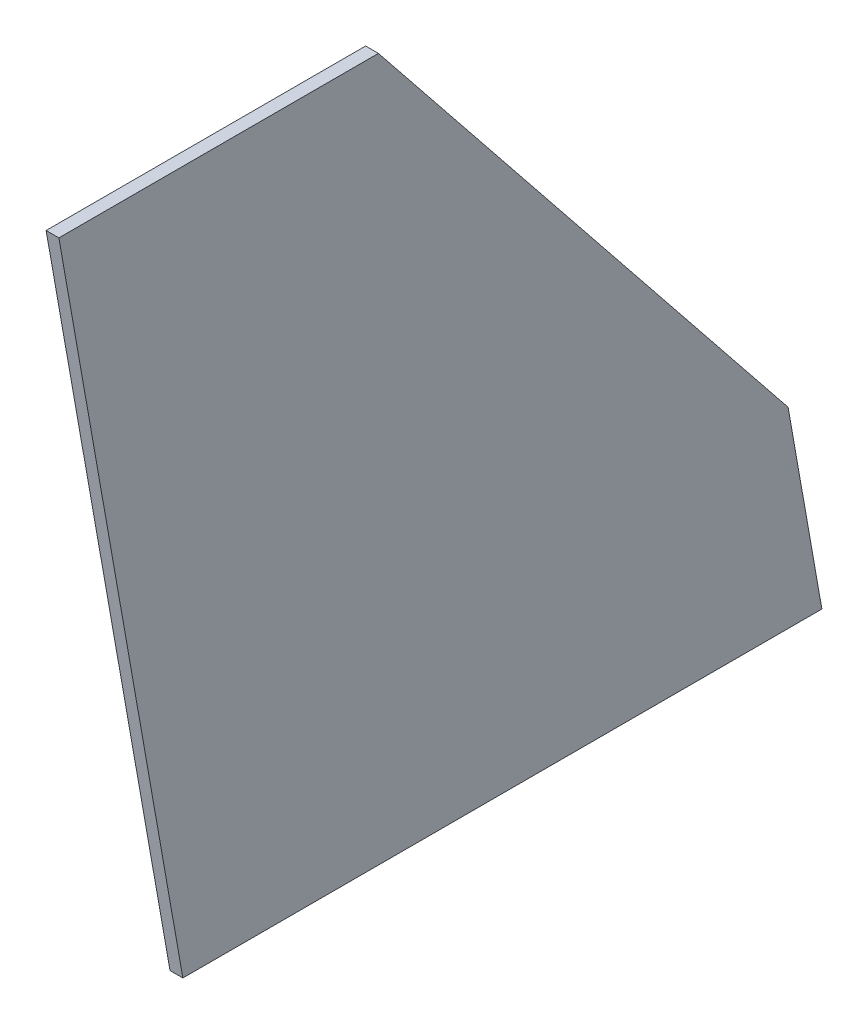
from build123d import *

# Parameters (mm, degrees)
BOSS_EXTRUDE1_DEPTH      = 1.27
BOSS_EXTRUDE1_DEPTH_BACK = 1.27


with BuildPart() as part:
    # Sketch1 → Boss-Extrude1 (new, two sides: drawn at the far end of the back side and taken through both)
    with BuildSketch(Plane(origin=(0, 0, 0), x_dir=(0, 0, -1), z_dir=(1, 0, 0)).offset(-BOSS_EXTRUDE1_DEPTH_BACK)):
        Polygon((0, 0), (127, 0), (120.281942035, 38.1), (38.867120795, 139.7), (-24.632879205, 139.7), align=None)
    extrude(amount=BOSS_EXTRUDE1_DEPTH + BOSS_EXTRUDE1_DEPTH_BACK)


solid = part.part
